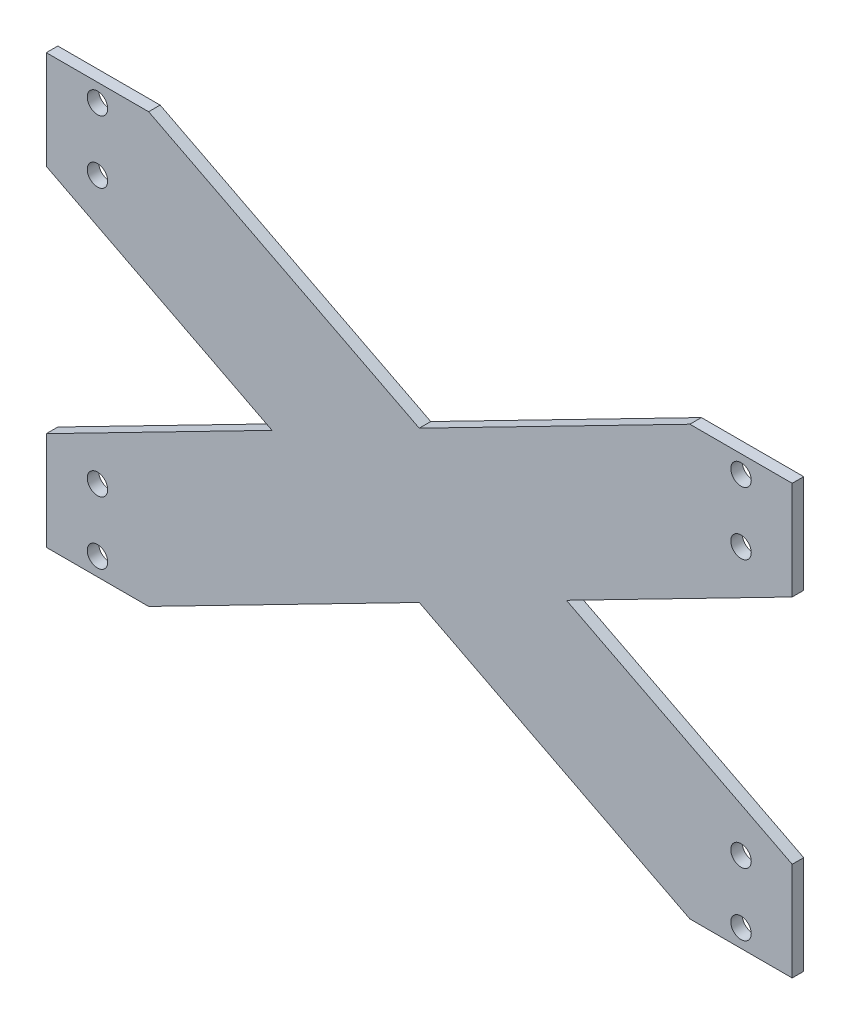
from build123d import *

# Parameters (mm, degrees)
SKETCH1_R           = 4
BOSS_EXTRUDE1_DEPTH = 4.5


with BuildPart() as part:
    # Sketch1 → Boss-Extrude1 (new body)
    with BuildSketch(Plane.XY):
        Polygon((152.142010442, -92.754372019), (94.597049202, -63.25), (6.342010442, -108.5), (6.342010442, -147), (46.342010442, -147), align=None)
        with Locations((26.342010442, -140)):
            Circle(SKETCH1_R, mode=Mode.SUBTRACT)
        with Locations((26.342010442, -115.5)):
            Circle(SKETCH1_R, mode=Mode.SUBTRACT)
        Polygon((152.142010442, -33.745627981), (94.597049202, -63.25), (152.142010442, -92.754372019), (209.686971683, -63.25), align=None)
        Polygon((6.342010442, 20.5), (6.342010442, -18), (94.597049202, -63.25), (152.142010442, -33.745627981), (46.342010442, 20.5), align=None)
        with Locations((26.342010442, -11)):
            Circle(SKETCH1_R, mode=Mode.SUBTRACT)
        with Locations((26.342010442, 13.5)):
            Circle(SKETCH1_R, mode=Mode.SUBTRACT)
        Polygon((257.942010442, 20.5), (152.142010442, -33.745627981), (209.686971683, -63.25), (297.942010442, -18), (297.942010442, 20.5), align=None)
        with Locations((277.942010442, -11)):
            Circle(SKETCH1_R, mode=Mode.SUBTRACT)
        with Locations((277.942010442, 13.5)):
            Circle(SKETCH1_R, mode=Mode.SUBTRACT)
        Polygon((209.686971683, -63.25), (152.142010442, -92.754372019), (257.942010442, -147), (297.942010442, -147), (297.942010442, -108.5), align=None)
        with Locations((277.942010442, -140)):
            Circle(SKETCH1_R, mode=Mode.SUBTRACT)
        with Locations((277.942010442, -115.5)):
            Circle(SKETCH1_R, mode=Mode.SUBTRACT)
    extrude(amount=BOSS_EXTRUDE1_DEPTH)


solid = part.part
